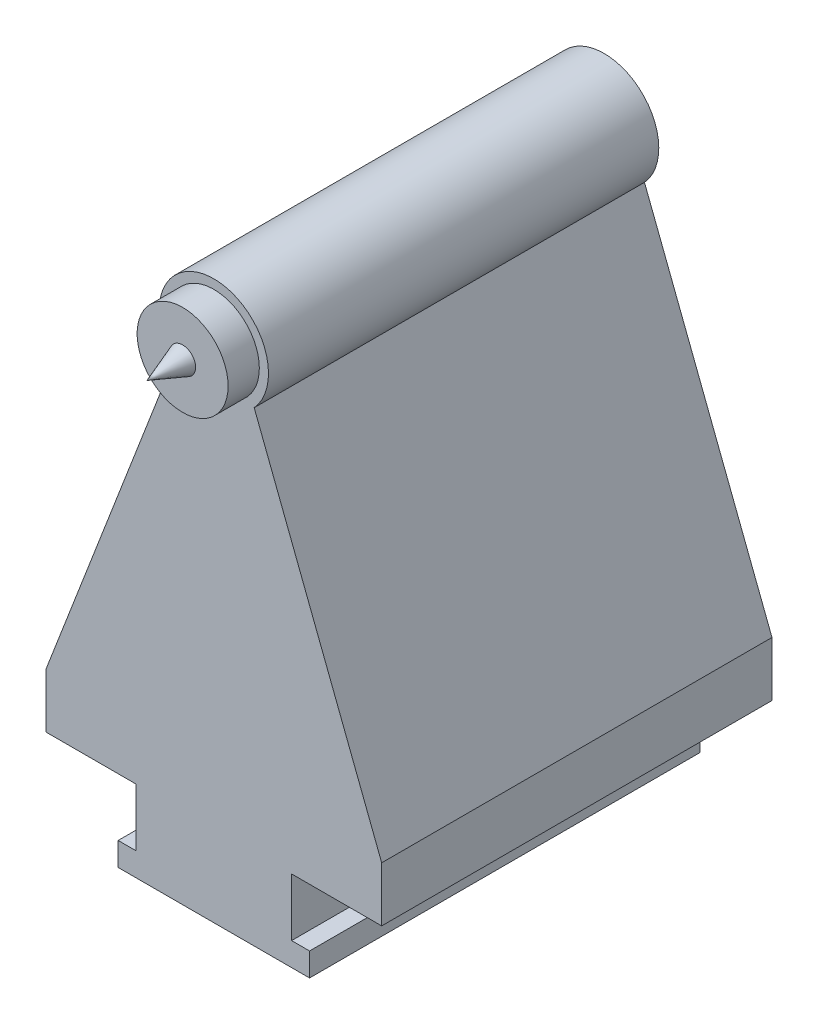
from build123d import *

# Parameters (mm, degrees)
SZKIC1_R                    = 35
DODANIE_WYCI_GNI_CIE2_DEPTH = 250
SZKIC4_R                    = 29.129576732
DODANIE_WYCI_GNI_CIE3_DEPTH = 20
SZKIC5_R                    = 8.316
DODANIE_WYCI_GNI_CIE4_DEPTH = 36
DODANIE_WYCI_GNI_CIE4_TAPER = 20


with BuildPart() as part:
    # Szkic1 → Dodanie-wyciągnięcie2 (new body)
    with BuildSketch(Plane.XY):
        with BuildLine():
            Line((12.5, 179), (12.5, 144))
            Line((12.5, 144), (70.2, 144))
            Line((70.2, 144), (70.2, 107))
            Line((70.2, 107), (58.7, 107))
            Line((58.7, 107), (58.7, 92))
            Line((58.7, 92), (181.3, 92))
            Line((181.3, 92), (181.3, 107))
            Line((181.3, 107), (169.8, 107))
            Line((169.8, 107), (169.8, 144))
            Line((169.8, 144), (227.5, 144))
            Line((227.5, 144), (227.5, 179))
            Line((227.5, 179), (145.832850365, 390.615092801))
            ThreePointArc((145.832850365, 390.615092801), (120, 379.23), (94.167149635, 390.615092801))
            Line((94.167149635, 390.615092801), (12.5, 179))
        make_face()
        with Locations((120, 414.23)):
            Circle(SZKIC1_R)
    extrude(amount=DODANIE_WYCI_GNI_CIE2_DEPTH)

    # Szkic4 → Dodanie-wyciągnięcie3 (add)
    with BuildSketch(Plane.XY.offset(250)):
        with Locations((120, 414.23)):
            Circle(SZKIC4_R)
    extrude(amount=DODANIE_WYCI_GNI_CIE3_DEPTH)

    # Szkic5 → Dodanie-wyciągnięcie4 (add)
    with BuildSketch(Plane.XY.offset(270)):
        with Locations((120, 414.23)):
            Circle(SZKIC5_R)
    extrude(amount=DODANIE_WYCI_GNI_CIE4_DEPTH, taper=DODANIE_WYCI_GNI_CIE4_TAPER)


solid = part.part
